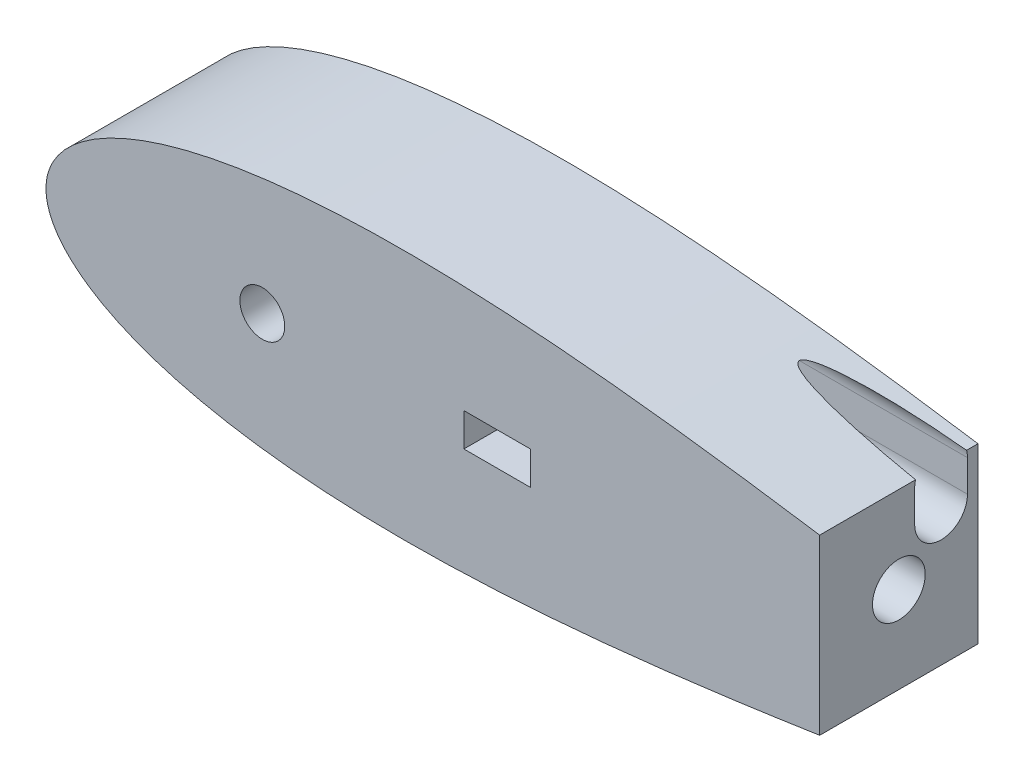
from build123d import *

# Parameters (mm, degrees)
BOSS_EXTRUDE1_DEPTH     = 76.2
SKETCH3_R               = 10.795
CUT_EXTRUDE2_DEPTH      = 76.2
SKETCH6_R               = 6.35
CUT_EXTRUDE3_DEPTH      = 53.34
CUT_EXTRUDE3_DEPTH_BACK = 0.000254
SKETCH7_R               = 1.5875
CUT_EXTRUDE4_DEPTH      = 30.48
SKETCH8_W               = 304.8
SKETCH8_H               = 127
CUT_EXTRUDE5_DEPTH      = 76.2
SKETCH9_R               = 12.7
CUT_EXTRUDE6_DEPTH      = 101.6
SKETCH10_R              = 3.175
CUT_EXTRUDE7_DEPTH      = 57.15
SKETCH11_R              = 5.08
CUT_EXTRUDE8_DEPTH      = 6.35
SKETCH12_R              = 3.175
CUT_EXTRUDE9_DEPTH      = 6.35
CUT_EXTRUDE10_DEPTH     = 198.458047838
SKETCH15_W              = 87.376
SKETCH15_H              = 60.96
CUT_EXTRUDE11_DEPTH     = 33.299999948
SKETCH17_W              = 32.000000008
SKETCH17_H              = 16.000000004
CUT_EXTRUDE12_DEPTH     = 50.8
SKETCH18_R              = 1.5
CUT_EXTRUDE13_DEPTH     = 25.4
SKETCH19_W              = 53.34
SKETCH19_H              = 21.59
CUT_EXTRUDE14_DEPTH     = 66.04


with BuildPart() as part:
    # Sketch1 → Boss-Extrude1 (new body)
    with BuildSketch(Plane.XY):
        with BuildLine():
            Line((643.966787522, 0), (643.599082689, 0))
            Line((643.599082689, 0), (643.599082689, -1.016))
            ThreePointArc((643.599082689, -1.016), (643.872033494, -0.540245973), (643.966787522, 0))
        make_face()
        with BuildLine():
            Line((643.599082689, -1.016), (643.599082689, 0))
            Line((643.599082689, 0), (641.567082689, 0))
            ThreePointArc((641.567082689, 0), (642.269121423, -1.135922533), (643.599082689, -1.016))
        make_face()
        with BuildLine():
            Line((641.567082689, 0), (643.599082689, 0))
            Line((643.599082689, 0), (643.966787522, 0))
            ThreePointArc((643.966787522, 0), (643.547407924, 1.075012082), (642.510849283, 1.582039112))
            add(Edge.make_bspline(
                [(642.510849283, 1.582039112), (641.993392355, 1.625070631), (638.093728429, 1.953546407), (630.413817462, 2.663385493), (619.014124193, 3.849253664), (606.374988512, 5.304428983), (592.543922516, 7.037634907), (577.585454095, 9.050636147), (561.564270734, 11.338919625), (544.549749946, 13.890665375), (526.614143658, 16.687720753), (507.832591566, 19.705111663), (488.282710288, 22.911672601), (468.044367735, 26.27043606), (447.199424328, 29.739007432), (425.831595832, 33.270324121), (404.02631566, 36.813220545), (381.870662856, 40.313266856), (359.453314895, 43.713502532), (336.86454415, 46.955447457), (314.196207315, 49.979843895), (291.541767704, 52.727712704), (268.996310773, 55.141201012), (246.65655865, 57.164603829), (224.620860897, 58.745176641), (202.989192599, 59.8341217), (181.863132616, 60.387506142), (161.345829027, 60.366961324), (141.542033828, 59.739895824), (122.558104573, 58.481758104), (104.502313427, 56.574303932), (87.485018636, 54.008935199), (71.619696083, 50.784752003), (57.023709725, 46.912543066), (43.82045433, 42.41500246), (32.141645239, 37.332204029), (22.129107375, 31.731455339), (13.932423524, 25.726412106), (7.689616489, 19.513207632), (3.463136343, 13.420354421), (1.106333228, 7.923389435), (0.154611582, 3.513796615), (0, 1.007496172), (0, 0)],
                knots=[0.020157042, 0.020157042, 0.020157042, 0.020157042, 0.021270888, 0.028552555, 0.036780684, 0.045920102, 0.055931764, 0.066772884, 0.07839713, 0.090754827, 0.103793165, 0.117456432, 0.131686226, 0.146421738, 0.161599998, 0.177156133, 0.193023668, 0.209134786, 0.225420633, 0.241811602, 0.258237647, 0.274628557, 0.290914287, 0.307025229, 0.322892517, 0.338448342, 0.353626207, 0.368361232, 0.382590428, 0.396252961, 0.409290412, 0.42164701, 0.433269881, 0.444109249, 0.45411864, 0.463255055, 0.471479114, 0.478755289, 0.485052318, 0.490344026, 0.494609833, 0.497833231, 0.5, 0.5, 0.5, 0.5], degree=3))
            Line((0, 0), (27.94, 0))
            ThreePointArc((27.94, 0), (40.64, 12.7), (53.34, 0))
            Line((53.34, 0), (93.345, 0))
            ThreePointArc((93.345, 0), (104.14, 10.795), (114.935, 0))
            Line((114.935, 0), (460.660965279, 0))
            Line((460.660965279, 0), (473.360965279, 0))
            Line((473.360965279, 0), (641.567082689, 0))
        make_face()
        with BuildLine():
            ThreePointArc((642.510849283, -1.582039112), (643.111845681, -1.408373102), (643.599082689, -1.016))
            ThreePointArc((643.599082689, -1.016), (642.269121423, -1.135922533), (641.567082689, 0))
            Line((641.567082689, 0), (473.360965279, 0))
            Line((473.360965279, 0), (460.660965279, 0))
            Line((460.660965279, 0), (114.935, 0))
            ThreePointArc((114.935, 0), (104.14, -10.795), (93.345, 0))
            Line((93.345, 0), (53.34, 0))
            ThreePointArc((53.34, 0), (40.64, -12.7), (27.94, 0))
            Line((27.94, 0), (0, 0))
            add(Edge.make_bspline(
                [(0, 0), (0, -1.007496172), (0.154611582, -3.513796615), (1.106333228, -7.923389435), (3.463136343, -13.420354421), (7.689616489, -19.513207632), (13.932423524, -25.726412106), (22.129107375, -31.731455339), (32.141645239, -37.332204029), (43.82045433, -42.41500246), (57.023709725, -46.912543066), (71.619696083, -50.784752003), (87.485018636, -54.008935199), (104.502313427, -56.574303932), (122.558104573, -58.481758104), (141.542033828, -59.739895824), (161.345829027, -60.366961324), (181.863132616, -60.387506142), (202.989192599, -59.8341217), (224.620860897, -58.745176641), (246.65655865, -57.164603829), (268.996310773, -55.141201012), (291.541767704, -52.727712704), (314.196207315, -49.979843895), (336.86454415, -46.955447457), (359.453314895, -43.713502532), (381.870662856, -40.313266856), (404.02631566, -36.813220545), (425.831595832, -33.270324121), (447.199424328, -29.739007432), (468.044367735, -26.27043606), (488.282710288, -22.911672601), (507.832591566, -19.705111663), (526.614143658, -16.687720753), (544.549749946, -13.890665375), (561.564270734, -11.338919625), (577.585454095, -9.050636147), (592.543922516, -7.037634907), (606.374988512, -5.304428983), (619.014124193, -3.849253664), (630.413817462, -2.663385493), (638.093728429, -1.953546407), (641.993392355, -1.625070631), (642.510849283, -1.582039112)],
                knots=[0.5, 0.5, 0.5, 0.5, 0.502166769, 0.505390167, 0.509655974, 0.514947682, 0.521244711, 0.528520886, 0.536744945, 0.54588136, 0.555890751, 0.566730119, 0.57835299, 0.590709588, 0.603747039, 0.617409572, 0.631638768, 0.646373793, 0.661551658, 0.677107483, 0.692974771, 0.709085713, 0.725371443, 0.741762353, 0.758188398, 0.774579367, 0.790865214, 0.806976332, 0.822843867, 0.838400002, 0.853578262, 0.868313774, 0.882543568, 0.896206835, 0.909245173, 0.92160287, 0.933227116, 0.944068236, 0.954079898, 0.963219316, 0.971447445, 0.978729112, 0.979842958, 0.979842958, 0.979842958, 0.979842958], degree=3))
        make_face()
        with BuildLine():
            ThreePointArc((643.966787522, 0), (643.872033494, -0.540245973), (643.599082689, -1.016))
            ThreePointArc((643.599082689, -1.016), (643.111845681, -1.408373102), (642.510849283, -1.582039112))
            add(Edge.make_bspline(
                [(642.510849283, -1.582039112), (644.922074617, -1.381522545), (649.798936594, -1.000308437), (656.504964311, -0.543558383), (662.850933168, -0.234427605), (666.344759683, -0.054696708), (670.56, -0.015678595), (670.56, 0)],
                knots=[0.979842958, 0.979842958, 0.979842958, 0.979842958, 0.985033212, 0.990332793, 0.994605218, 0.997832222, 1, 1, 1, 1], degree=3))
            add(Edge.make_bspline(
                [(670.56, 0), (670.56, 0.015678595), (666.344759683, 0.054696708), (662.850933168, 0.234427605), (656.504964311, 0.543558383), (649.798936594, 1.000308437), (644.922074617, 1.381522545), (642.510849283, 1.582039112)],
                knots=[0, 0, 0, 0, 0.002167778, 0.005394782, 0.009667207, 0.014966788, 0.020157042, 0.020157042, 0.020157042, 0.020157042], degree=3))
            ThreePointArc((642.510849283, 1.582039112), (643.547407924, 1.075012082), (643.966787522, 0))
        make_face()
        with BuildLine():
            ThreePointArc((53.34, 0), (40.64, 12.7), (27.94, 0))
            Line((27.94, 0), (53.34, 0))
        make_face()
        with BuildLine():
            Line((53.34, 0), (27.94, 0))
            ThreePointArc((27.94, 0), (40.64, -12.7), (53.34, 0))
        make_face()
        with BuildLine():
            ThreePointArc((93.345, 0), (104.14, -10.795), (114.935, 0))
            Line((114.935, 0), (93.345, 0))
        make_face()
        with BuildLine():
            Line((93.345, 0), (114.935, 0))
            ThreePointArc((114.935, 0), (104.14, 10.795), (93.345, 0))
        make_face()
    extrude(amount=BOSS_EXTRUDE1_DEPTH)

    # Sketch3 → Cut-Extrude2 (cut)
    with BuildSketch(Plane.XY.offset(76.2)):
        with Locations((104.139232412, 0)):
            Circle(SKETCH3_R)
    extrude(amount=-CUT_EXTRUDE2_DEPTH, mode=Mode.SUBTRACT)

    # Sketch6 → Cut-Extrude3 (cut, two sides)
    with BuildSketch(Plane(origin=(0, 0, 0), x_dir=(0, 0, -1), z_dir=(1, 0, 0))) as cut_extrude3_sk:
        with Locations((-20.32, 0)):
            Circle(SKETCH6_R)
    extrude(amount=CUT_EXTRUDE3_DEPTH, mode=Mode.SUBTRACT)
    extrude(cut_extrude3_sk.sketch, amount=-CUT_EXTRUDE3_DEPTH_BACK, mode=Mode.SUBTRACT)

    # Sketch7 → Cut-Extrude4 (cut)
    with BuildSketch(Plane(origin=(0, 0, 0), x_dir=(-1, 0, 0), z_dir=(0, 0, -1))):
        with Locations((-38.1, 0)):
            Circle(SKETCH7_R)
        with Locations((-50.8, 0)):
            Circle(SKETCH7_R)
    extrude(amount=-CUT_EXTRUDE4_DEPTH, mode=Mode.SUBTRACT)

    # Sketch8 → Cut-Extrude5 (cut)
    with BuildSketch(Plane(origin=(0, 0, 0), x_dir=(-1, 0, 0), z_dir=(0, 0, -1))):
        with Locations((-524.843319628, 0.490119432)):
            Rectangle(SKETCH8_W, SKETCH8_H)
    extrude(amount=-CUT_EXTRUDE5_DEPTH, mode=Mode.SUBTRACT)

    # Sketch9 → Cut-Extrude6 (cut)
    with BuildSketch(Plane(origin=(372.443319628, 0, 0), x_dir=(0, 0, -1), z_dir=(1, 0, 0))):
        with Locations((-38.1, 0)):
            Circle(SKETCH9_R)
    extrude(amount=-CUT_EXTRUDE6_DEPTH, mode=Mode.SUBTRACT)

    # Sketch10 → Cut-Extrude7 (cut)
    with BuildSketch(Plane(origin=(0, 0, 0), x_dir=(-1, 0, 0), z_dir=(0, 0, -1))):
        with Locations((-343.868319647, 0)):
            Circle(SKETCH10_R)
        with Locations((-286.718319647, 0)):
            Circle(SKETCH10_R)
    extrude(amount=-CUT_EXTRUDE7_DEPTH, mode=Mode.SUBTRACT)

    # Sketch11 → Cut-Extrude8 (cut)
    with BuildSketch(Plane(origin=(0, 0, 0), x_dir=(-1, 0, 0), z_dir=(0, 0, -1))):
        with Locations((-286.718319647, 0)):
            Circle(SKETCH11_R)
        with Locations((-343.868319647, 0)):
            Circle(SKETCH11_R)
    extrude(amount=-CUT_EXTRUDE8_DEPTH, mode=Mode.SUBTRACT)

    # Sketch12 → Cut-Extrude9 (cut)
    with BuildSketch(Plane(origin=(0, 0, 0), x_dir=(-1, 0, 0), z_dir=(0, 0, -1))):
        with Locations((-38.1, 0)):
            Circle(SKETCH12_R)
        with Locations((-50.8, 0)):
            Circle(SKETCH12_R)
    extrude(amount=-CUT_EXTRUDE9_DEPTH, mode=Mode.SUBTRACT)

    # Sketch13 → Cut-Extrude10 (cut)
    with BuildSketch(Plane(origin=(372.443319628, 0, 0), x_dir=(0, 0, -1), z_dir=(1, 0, 0))):
        with BuildLine():
            Line((-30.48, 23.232341673), (-30.48, 38.472341673))
            ThreePointArc((-30.48, 38.472341673), (-17.78, 51.172341673), (-5.08, 38.472341673))
            Line((-5.08, 38.472341673), (-5.08, 23.232341673))
            ThreePointArc((-5.08, 23.232341673), (-17.78, 10.532341673), (-30.48, 23.232341673))
        make_face()
    extrude(amount=-CUT_EXTRUDE10_DEPTH, mode=Mode.SUBTRACT)

    # Sketch15 → Cut-Extrude11 (cut)
    with BuildSketch(Plane(origin=(0, 0, 0), x_dir=(-1, 0, 0), z_dir=(0, 0, -1))):
        with Locations((-217.673271809, 0)):
            Rectangle(SKETCH15_W, SKETCH15_H)
    extrude(amount=-CUT_EXTRUDE11_DEPTH, mode=Mode.SUBTRACT)

    # Sketch17 → Cut-Extrude12 (cut)
    with BuildSketch(Plane(origin=(0, 0, 33.299999948), x_dir=(-1, 0, 0), z_dir=(0, 0, -1))):
        with Locations((-217.171095775, 0)):
            Rectangle(SKETCH17_W, SKETCH17_H)
    extrude(amount=-CUT_EXTRUDE12_DEPTH, mode=Mode.SUBTRACT)

    # Sketch18 → Cut-Extrude13 (cut)
    with BuildSketch(Plane(origin=(0, 0, 33.299999948), x_dir=(-1, 0, 0), z_dir=(0, 0, -1))):
        with Locations((-199.471095771, 0)):
            Circle(SKETCH18_R)
        with Locations((-234.871095681, 0)):
            Circle(SKETCH18_R)
    extrude(amount=-CUT_EXTRUDE13_DEPTH, mode=Mode.SUBTRACT)

    # Sketch19 → Cut-Extrude14 (cut)
    with BuildSketch(Plane(origin=(0, 0, 0), x_dir=(-1, 0, 0), z_dir=(0, 0, -1))):
        with Locations((-139.373905779, 39.146670369)):
            Rectangle(SKETCH19_W, SKETCH19_H)
    extrude(amount=-CUT_EXTRUDE14_DEPTH, mode=Mode.SUBTRACT)


solid = part.part
